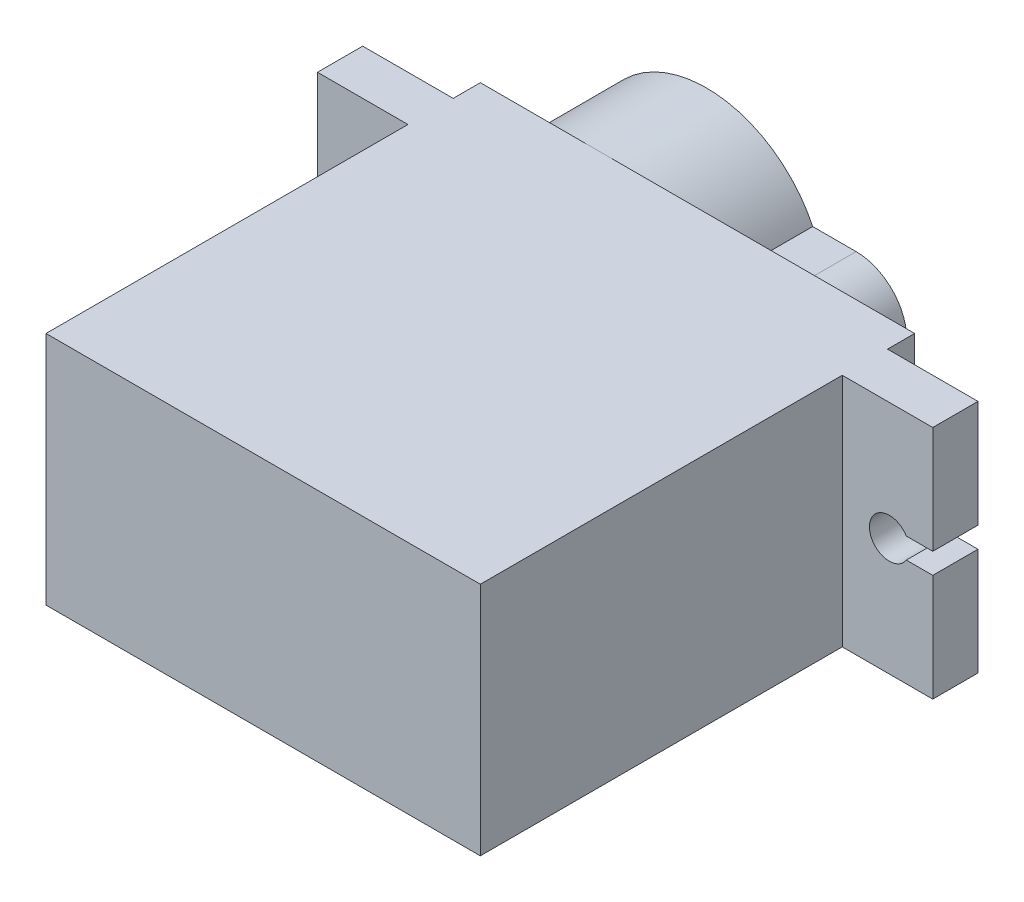
from build123d import *

# Parameters (mm, degrees)
SKETCH_1_W          = 24
SKETCH_1_H          = 13
EXTRUDE_1_DEPTH     = 24
SKETCH_2_W          = 34
SKETCH_2_H          = 13
EXTRUDE_2_DEPTH     = 2.5
MM_13_D             = 2.2
MM_13_DEPTH         = 1.076990406
MM_13_TIP           = 0.923009594
CUT_EXTRUDE_1_DEPTH = 3.5
EXTRUDE_3_DEPTH     = 6
SKETCH_42_R         = 1
CUT_EXTRUDE_2_DEPTH = 4


with BuildPart() as part:
    # 草图1 → 凸台-拉伸1 (new body)
    with BuildSketch(Plane.XY):
        with Locations((12, 6.5)):
            Rectangle(SKETCH_1_W, SKETCH_1_H)
    extrude(amount=EXTRUDE_1_DEPTH)

    # 草图2 → 凸台-拉伸2 (add)
    with BuildSketch(Plane.XY.offset(1.5)):
        with Locations((12, 6.5)):
            Rectangle(SKETCH_2_W, SKETCH_2_H)
    extrude(amount=EXTRUDE_2_DEPTH)

    # 大小mm 暗销孔13
    with Locations(Plane(origin=(0, 0, 1.5), x_dir=(-1, 0, 0), z_dir=(0, 0, -1))):
        with Locations((2.6, 10), (2.6, 3), (-26.6, 10), (-26.6, 3)):
            Hole(MM_13_D / 2, depth=MM_13_DEPTH)
            with Locations((0, 0, -(MM_13_DEPTH + MM_13_TIP / 2))):  # 100° drill point
                Cone(0, MM_13_D / 2, MM_13_TIP, mode=Mode.SUBTRACT)

    # 草图6 → 切除-拉伸1 (cut)
    with BuildSketch(Plane.XY.offset(1.5)):
        with BuildLine():
            Line((-5, 7.074764733), (-3.537894185, 7.074764733))
            ThreePointArc((-3.537894185, 7.074764733), (-1.5, 6.5), (-3.537894185, 5.925235267))
            Line((-3.537894185, 5.925235267), (-5, 5.925235267))
            Line((-5, 5.925235267), (-5, 7.074764733))
        make_face()
        with BuildLine():
            Line((29, 5.925235267), (27.537894185, 5.925235267))
            ThreePointArc((27.537894185, 5.925235267), (25.5, 6.5), (27.537894185, 7.074764733))
            Line((27.537894185, 7.074764733), (29, 7.074764733))
            Line((29, 7.074764733), (29, 5.925235267))
        make_face()
    extrude(amount=CUT_EXTRUDE_1_DEPTH, mode=Mode.SUBTRACT)

    # 草图27 → 凸台-拉伸3 (add)
    with BuildSketch(Plane(origin=(0, 0, 0), x_dir=(-1, 0, 0), z_dir=(0, 0, -1))):
        with BuildLine():
            Line((-14.765807305, 3.7), (-12.36600375, 3.7))
            ThreePointArc((-12.36600375, 3.7), (0, 6.5), (-12.36600375, 9.3))
            Line((-12.36600375, 9.3), (-14.765807305, 9.3))
            ThreePointArc((-14.765807305, 9.3), (-17.565807305, 6.5), (-14.765807305, 3.7))
        make_face()
    extrude(amount=EXTRUDE_3_DEPTH)

    # 草图42 → 切除-拉伸2 (cut)
    with BuildSketch(Plane(origin=(0, 0, -6), x_dir=(-1, 0, 0), z_dir=(0, 0, -1))):
        with Locations((-6.5, 6.5)):
            Circle(SKETCH_42_R)
    extrude(amount=-CUT_EXTRUDE_2_DEPTH, mode=Mode.SUBTRACT)


solid = part.part
